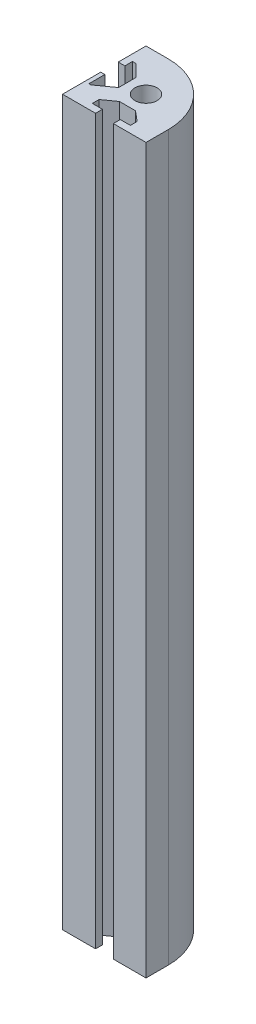
from build123d import *

# Parameters (mm, degrees)
CROQUIS1_R              = 4
SALIENTE_EXTRUIR1_DEPTH = 260


with BuildPart() as part:
    # Croquis1 → Saliente-Extruir1 (new body)
    with BuildSketch(Plane(origin=(0, 0, 0), x_dir=(1, 0, 0), z_dir=(0, 1, 0))):
        with BuildLine():
            Line((-7, 15), (-15, 15))
            Line((-15, 15), (-15, 5.027604917))
            Line((-15, 5.027604917), (-12.623437069, 5.027604917))
            Line((-12.623437069, 5.027604917), (-12.623437069, 7.752682341))
            Line((-12.623437069, 7.752682341), (-11.320548438, 7.752682341))
            Line((-11.320548438, 7.752682341), (-7, 3.432133903))
            Line((-7, 3.432133903), (-7, -2.861090311))
            Line((-7, -2.861090311), (-12.793007796, -7))
            Line((-12.793007796, -7), (-13.527286117, -7))
            Line((-13.527286117, -7), (-13.527286117, -1.25796789))
            Line((-13.527286117, -1.25796789), (-15, -1.25796789))
            Line((-15, -1.25796789), (-15, -15))
            Line((-15, -15), (-3.139941254, -15))
            Line((-3.139941254, -15), (-3.139941254, -12.505835019))
            Line((-3.139941254, -12.505835019), (-6.77895709, -12.505835019))
            Line((-6.77895709, -12.505835019), (-6.77895709, -10.079824462))
            Line((-6.77895709, -10.079824462), (-2.512909638, -7.031876702))
            Line((-2.512909638, -7.031876702), (3.25590476, -7.031876702))
            Line((3.25590476, -7.031876702), (6.894920596, -10.079824462))
            Line((6.894920596, -10.079824462), (6.894920596, -12.505835019))
            Line((6.894920596, -12.505835019), (3.25590476, -12.505835019))
            Line((3.25590476, -12.505835019), (3.25590476, -15))
            Line((3.25590476, -15), (15, -15))
            Line((15, -15), (15, -7))
            ThreePointArc((15, -7), (8.556349186, 8.556349186), (-7, 15))
        make_face()
        Circle(CROQUIS1_R, mode=Mode.SUBTRACT)
    extrude(amount=SALIENTE_EXTRUIR1_DEPTH)


solid = part.part
